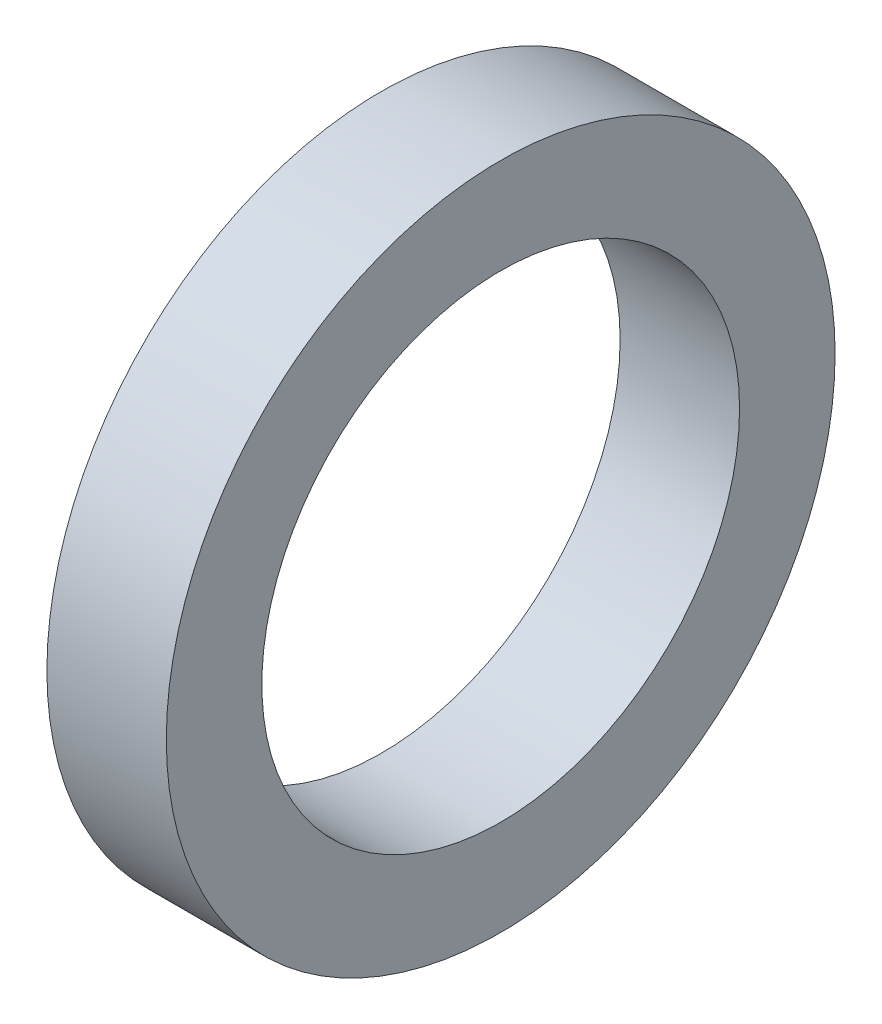
from build123d import *

# Parameters (mm, degrees)
SKETCH1_R           = 8.89
SKETCH1_R_2         = 6.35
BOSS_EXTRUDE1_DEPTH = 3.175


with BuildPart() as part:
    # Sketch1 → Boss-Extrude1 (new body)
    with BuildSketch(Plane(origin=(0, 0, 0), x_dir=(0, 0, -1), z_dir=(1, 0, 0))):
        Circle(SKETCH1_R)
        Circle(SKETCH1_R_2, mode=Mode.SUBTRACT)
    extrude(amount=BOSS_EXTRUDE1_DEPTH)


solid = part.part
